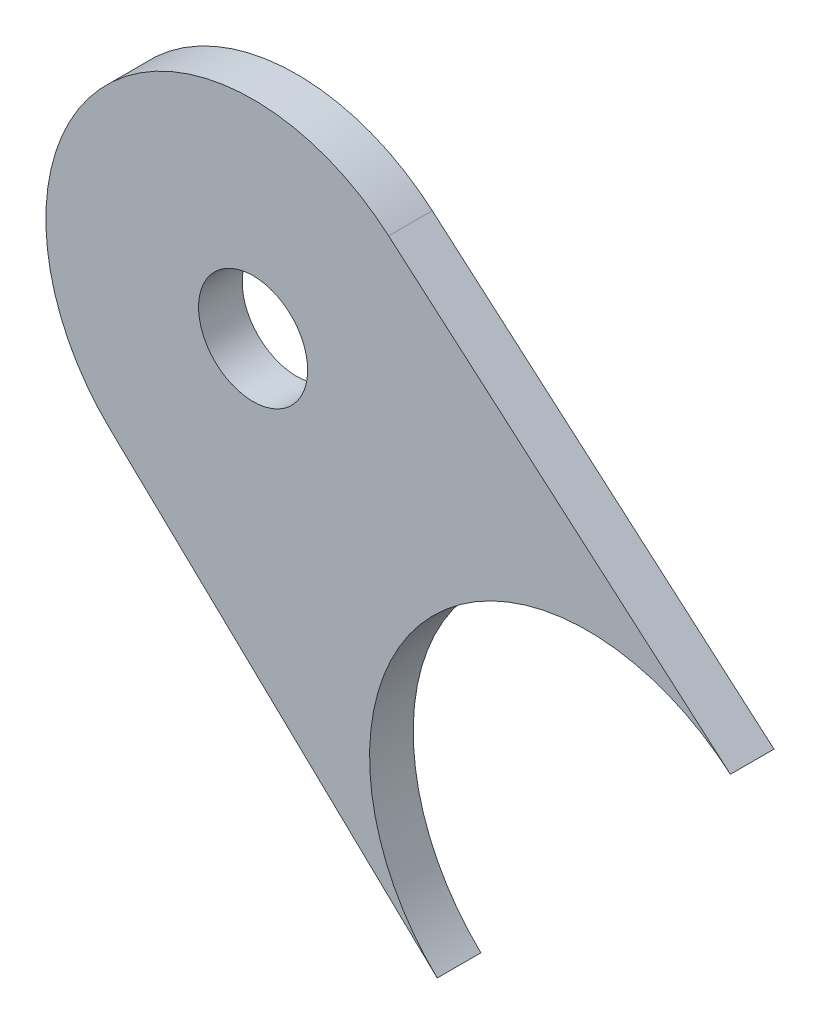
from build123d import *

# Parameters (mm, degrees)
BOSS_EXTRUDE3_START = 4.7625
SKETCH2_R           = 3.175
BOSS_EXTRUDE3_DEPTH = 2.54


with BuildPart() as part:
    # Sketch2 → Boss-Extrude3 (new body)
    with BuildSketch(Plane.XY.offset(BOSS_EXTRUDE3_START)):
        with BuildLine():
            Line((111.752654756, -67.172007853), (131.648348491, -84.372647625))
            ThreePointArc((131.648348491, -84.372647625), (113.938329585, -85.444576189), (114.582474398, -103.175308774))
            Line((114.582474398, -103.175308774), (95.540074367, -85.034535944))
            ThreePointArc((95.540074367, -85.034535944), (94.928136795, -68.190339989), (111.752654756, -67.172007853))
        make_face()
        with Locations((103.862003689, -76.298992609)):
            Circle(SKETCH2_R, mode=Mode.SUBTRACT)
    extrude(amount=BOSS_EXTRUDE3_DEPTH)


solid = part.part
